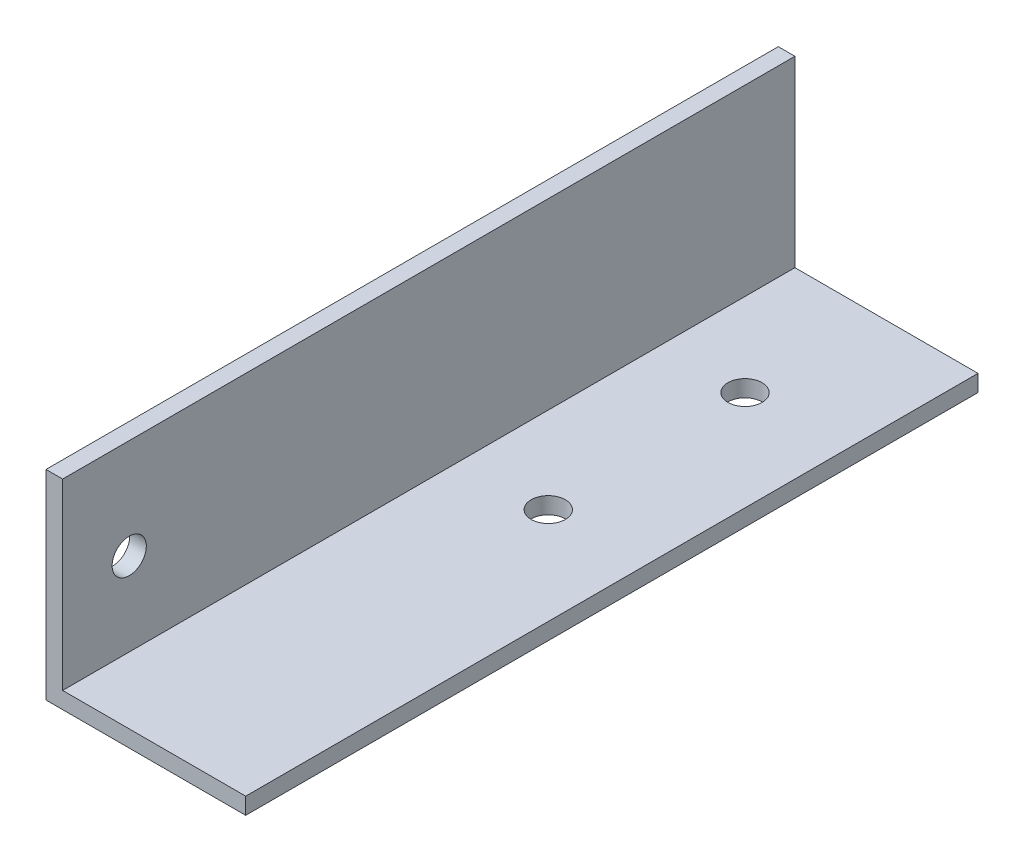
from build123d import *

# Parameters (mm, degrees)
BOSS_EXTRUDE1_DEPTH   = 69.85
F_4_CLEARANCE_HOLE1_D = 3.2639
F_4_CLEARANCE_HOLE2_D = 3.2639


with BuildPart() as part:
    # Sketch1 → Boss-Extrude1 (new body)
    with BuildSketch(Plane.XY):
        Polygon((0, 0), (0, 19.05), (1.5875, 19.05), (1.5875, 1.5875), (19.05, 1.5875), (19.05, 0), align=None)
    extrude(amount=BOSS_EXTRUDE1_DEPTH)

    # #4 Clearance Hole1 (through all)
    with Locations(Plane(origin=(1.5875, 0, 0), x_dir=(0, 0, -1), z_dir=(1, 0, 0))):
        with Locations((-63.5, 9.525)):
            Hole(F_4_CLEARANCE_HOLE1_D / 2)

    # #4 Clearance Hole2 (through all)
    with Locations(Plane(origin=(0, 1.5875, 0), x_dir=(1, 0, 0), z_dir=(0, 1, 0))):
        with Locations((9.525, -12.7), (9.807915651, -31.75)):
            Hole(F_4_CLEARANCE_HOLE2_D / 2)


solid = part.part
